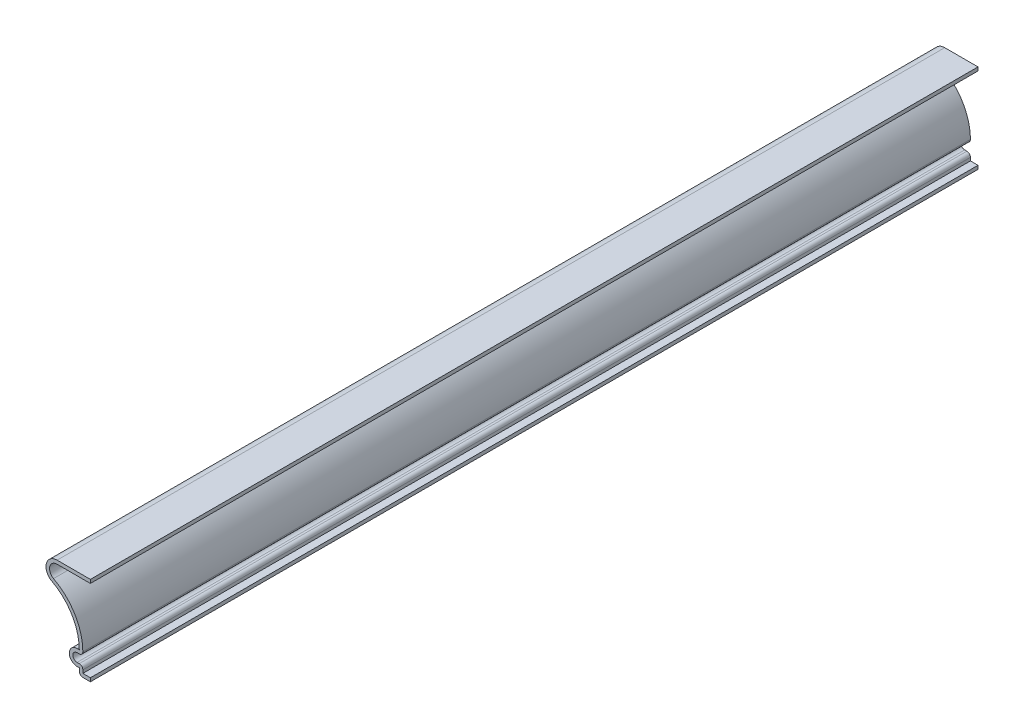
from build123d import *

# Parameters (mm, degrees)
EXTRUDE_THIN1_DEPTH = 317.5
FILLET1_R           = 1.27


with BuildPart() as part:
    # Sketch1 → Extrude-Thin1 (new body)
    with BuildSketch(Plane.XY):
        with BuildLine():
            Line((0, 31.75), (-11.90625, 31.75))
            ThreePointArc((-11.90625, 31.75), (-15.756503047, 28.743813262), (-13.773897059, 24.279411765))
            ThreePointArc((-13.773897059, 24.279411765), (-6.608099772, 17.466390137), (-3.96875, 7.9375))
            Line((-3.96875, 7.9375), (-4.7625, 7.9375))
            ThreePointArc((-4.7625, 7.9375), (-7.540625, 5.159375), (-4.7625, 2.38125))
            Line((-4.7625, 2.38125), (-3.96875, 2.38125))
            Line((-3.96875, 2.38125), (-3.96875, 0))
            Line((-3.96875, 0), (0, 0))
            Line((0, 0), (0, 1.27))
            Line((0, 1.27), (-2.69875, 1.27))
            Line((-2.69875, 1.27), (-2.69875, 3.65125))
            Line((-2.69875, 3.65125), (-4.7625, 3.65125))
            ThreePointArc((-4.7625, 3.65125), (-6.270625, 5.159375), (-4.7625, 6.6675))
            Line((-4.7625, 6.6675), (-2.7395407, 6.6675))
            ThreePointArc((-2.7395407, 6.6675), (-5.200957167, 17.569762939), (-13.17625, 25.4))
            ThreePointArc((-13.17625, 25.4), (-14.524422072, 28.435793018), (-11.90625, 30.48))
            Line((-11.90625, 30.48), (0, 30.48))
            Line((0, 30.48), (0, 31.75))
        make_face()
    extrude(amount=-EXTRUDE_THIN1_DEPTH)

    # Fillet1
    fillet1_edges = [part.edges().sort_by_distance(p)[0] for p in [
        (-3.96875, 0, -158.75),
        (-2.7395407, 6.6675, -158.75),
        (-2.69875, 3.65125, -158.75),
    ]]
    fillet(fillet1_edges, radius=FILLET1_R)


solid = part.part
